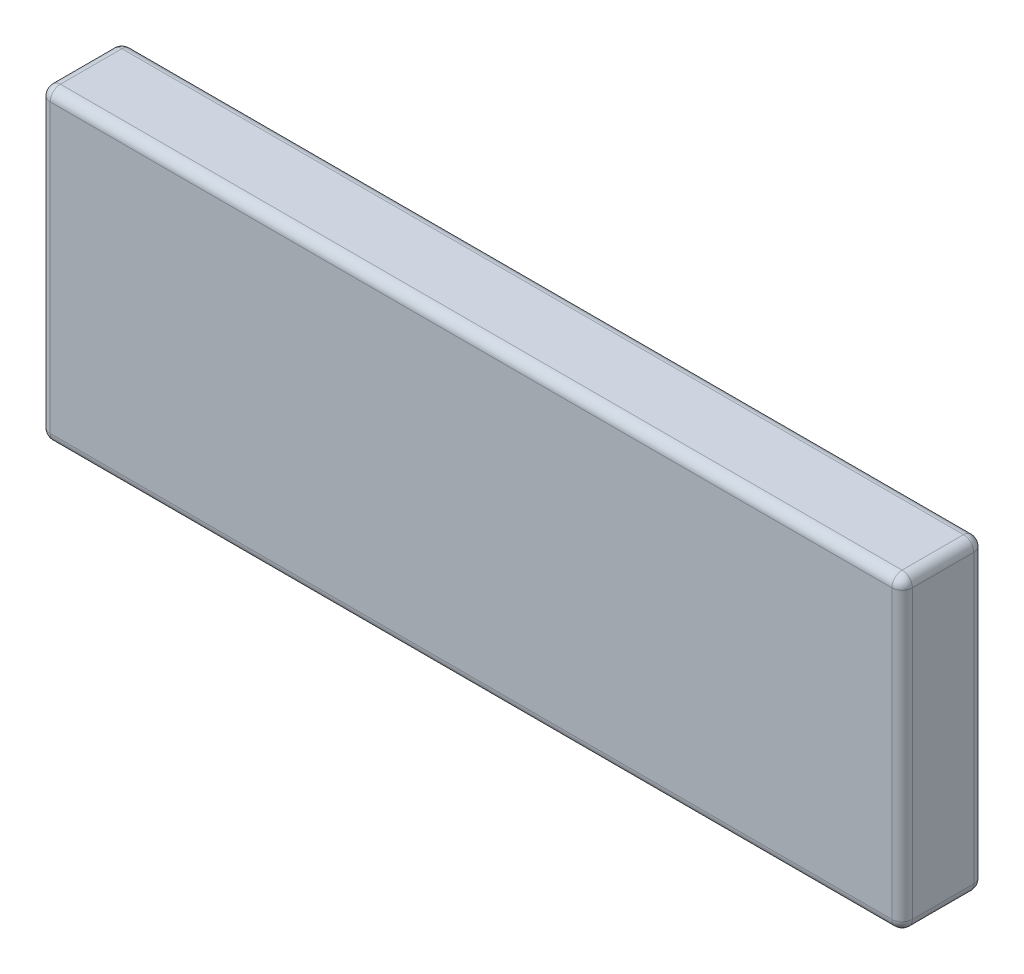
from build123d import *

# Parameters (mm, degrees)
SKETCH2_W           = 84.197623914
SKETCH2_H           = 30.043243078
BOSS_EXTRUDE1_DEPTH = 8
FILLET5_R           = 1


with BuildPart() as part:
    # Sketch2 → Boss-Extrude1 (new body)
    with BuildSketch(Plane.XY):
        with Locations((42.098811957, -15.021621539)):
            Rectangle(SKETCH2_W, SKETCH2_H)
    extrude(amount=BOSS_EXTRUDE1_DEPTH)

    # Fillet5
    fillet5_edges = [part.edges().sort_by_distance(p)[0] for p in [
        (84.197623914, -15.021621539, 8),
        (42.098811957, 0, 8),
        (0, -15.021621539, 8),
        (42.098811957, 0, 0),
        (84.197623914, -15.021621539, 0),
        (42.098811957, -30.043243078, 0),
        (0, -15.021621539, 0),
        (0, 0, 4),
        (84.197623914, 0, 4),
        (84.197623914, -30.043243078, 4),
        (0, -30.043243078, 4),
        (42.098811957, -30.043243078, 8),
    ]]
    fillet(fillet5_edges, radius=FILLET5_R)


solid = part.part
